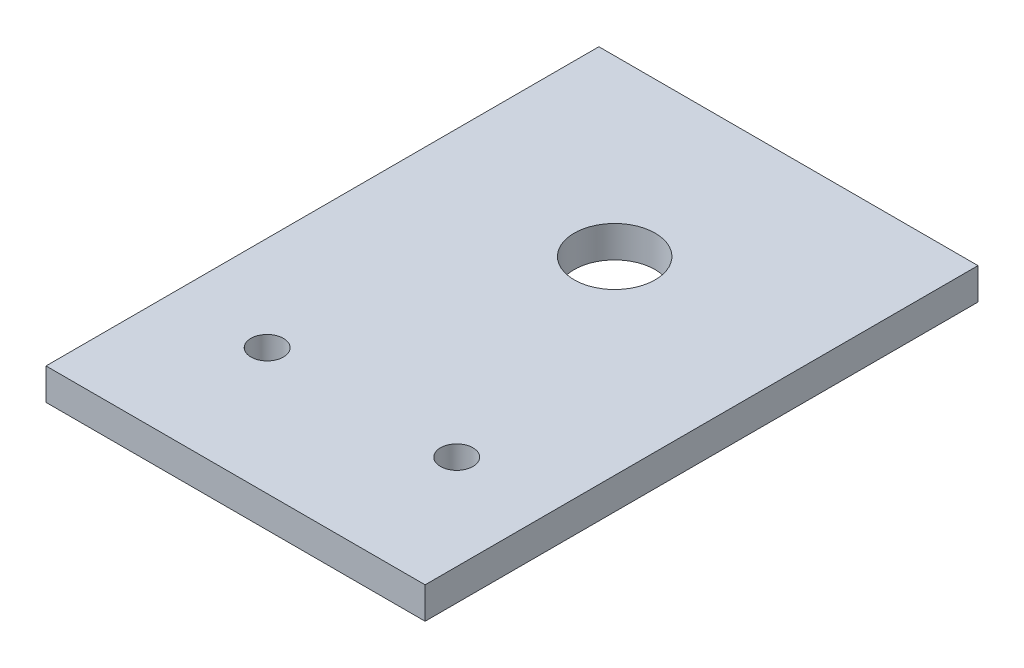
from build123d import *

# Parameters (mm, degrees)
SKETCH1_W           = 76.2
SKETCH1_H           = 111.125
BOSS_EXTRUDE1_DEPTH = 6.35
SKETCH2_R           = 3.2639
SKETCH2_R_2         = 8.13562
CUT_EXTRUDE1_DEPTH  = 7.35


with BuildPart() as part:
    # Sketch1 → Boss-Extrude1 (new body)
    with BuildSketch(Plane(origin=(0, 0, 0), x_dir=(1, 0, 0), z_dir=(0, 1, 0))):
        Rectangle(SKETCH1_W, SKETCH1_H)
    extrude(amount=BOSS_EXTRUDE1_DEPTH)

    # Sketch2 → Cut-Extrude1 (cut, through all)
    with BuildSketch(Plane(origin=(0, 0, 0), x_dir=(-1, 0, 0), z_dir=(0, -1, 0))):
        with Locations((-19.05, -30.1625)):
            Circle(SKETCH2_R)
        with Locations((19.05, -30.1625)):
            Circle(SKETCH2_R)
        with Locations((0, 20.6375)):
            Circle(SKETCH2_R_2)
    extrude(amount=-CUT_EXTRUDE1_DEPTH, mode=Mode.SUBTRACT)


solid = part.part
